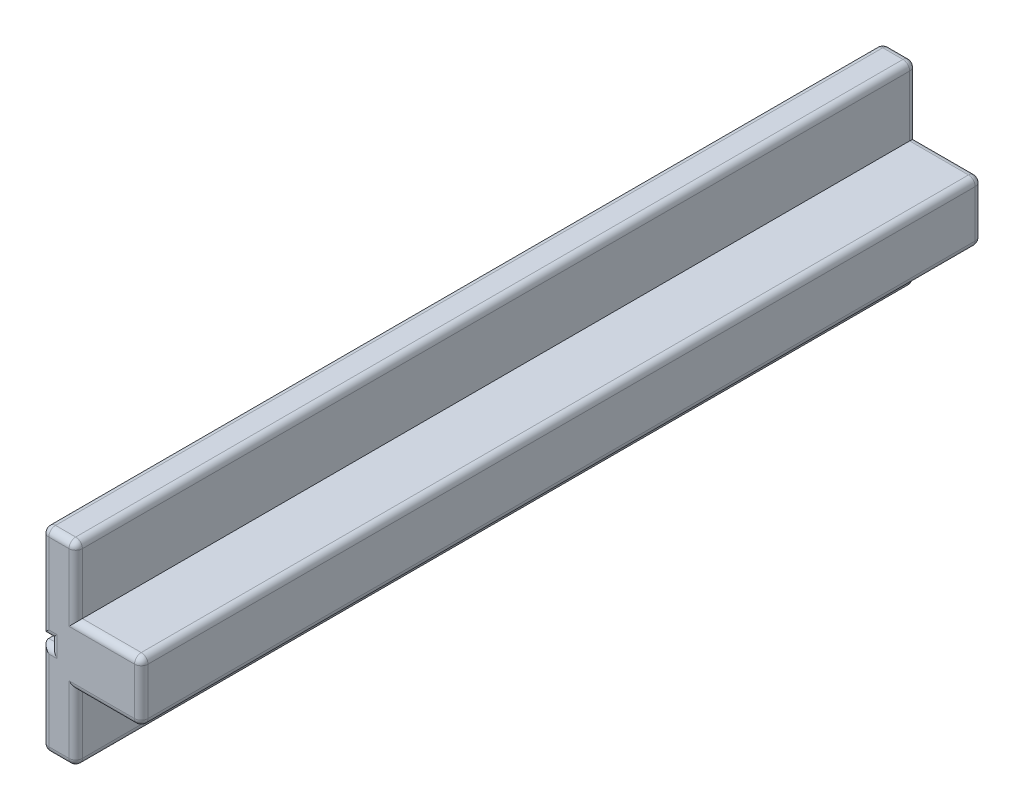
from build123d import *

# Parameters (mm, degrees)
AUFSATZ_LINEAR_AUSTRAGEN1_DEPTH = 25
VERRUNDUNG1_R                   = 0.2


with BuildPart() as part:
    # Skizze1 → Aufsatz-Linear austragen1 (new body)
    with BuildSketch(Plane.XY):
        Polygon((2.95, 2), (1, 2), (1, 0), (0, 0), (0, 2.79), (0.25, 2.79), (0.25, 3.01), (0, 3.01), (0, 5.8), (1, 5.8), (1, 3.8), (2.95, 3.8), align=None)
    extrude(amount=AUFSATZ_LINEAR_AUSTRAGEN1_DEPTH)

    # Verrundung1
    verrundung1_edges = [part.edges().sort_by_distance(p)[0] for p in [
        (0.5, 5.8, 0),
        (1, 4.8, 0),
        (0.25, 2.9, 25),
        (1.975, 3.8, 0),
        (2.95, 2.9, 0),
        (1.975, 2, 0),
        (1, 1, 0),
        (0.5, 0, 0),
        (0, 1.395, 0),
        (0.125, 2.79, 0),
        (0.25, 2.9, 0),
        (0.125, 3.01, 0),
        (0, 4.405, 0),
        (0.125, 2.79, 25),
        (0, 5.8, 12.5),
        (1, 5.8, 12.5),
        (0, 1.395, 25),
        (2.95, 3.8, 12.5),
        (2.95, 2, 12.5),
        (1, 0, 12.5),
        (0, 0, 12.5),
        (0.5, 0, 25),
        (1, 1, 25),
        (1.975, 2, 25),
        (2.95, 2.9, 25),
        (1.975, 3.8, 25),
        (1, 4.8, 25),
        (0.5, 5.8, 25),
        (0, 4.405, 25),
        (0.125, 3.01, 25),
    ]]
    fillet(verrundung1_edges, radius=VERRUNDUNG1_R)


solid = part.part
